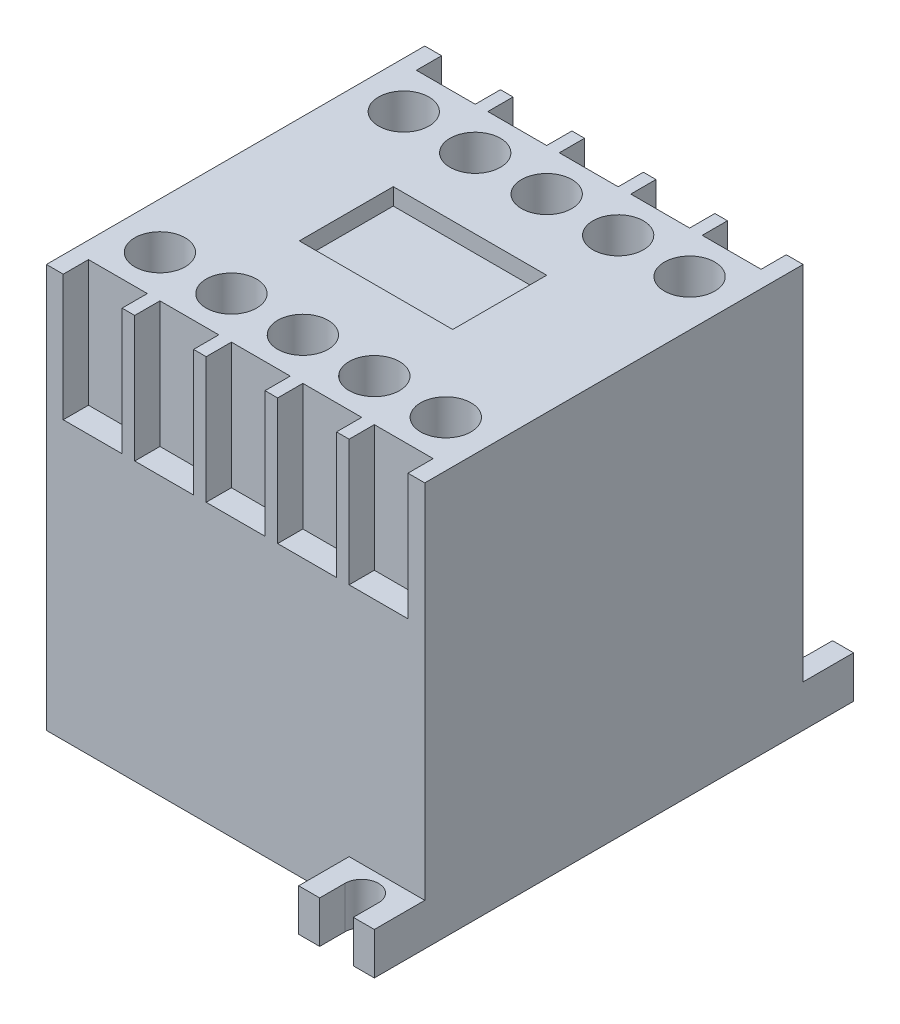
from build123d import *

# Parameters (mm, degrees)
SKETCH1_W           = 45
SKETCH1_H           = 45
BOSS_EXTRUDE1_DEPTH = 48
SKETCH2_W           = 7
SKETCH2_H           = 3
CUT_EXTRUDE1_DEPTH  = 15
SKETCH3_R           = 3
CUT_EXTRUDE2_DEPTH  = 8
SKETCH4_W           = 18.249611446
SKETCH4_H           = 11.178416291
CUT_EXTRUDE3_DEPTH  = 2
BOSS_EXTRUDE2_DEPTH = 5


with BuildPart() as part:
    # Sketch1 → Boss-Extrude1 (new body)
    with BuildSketch(Plane(origin=(0, 0, 0), x_dir=(1, 0, 0), z_dir=(0, 1, 0))):
        with Locations((22.5, 22.5)):
            Rectangle(SKETCH1_W, SKETCH1_H)
    extrude(amount=BOSS_EXTRUDE1_DEPTH)

    # Sketch2 → Cut-Extrude1 (cut)
    with BuildSketch(Plane(origin=(0, 48, 0), x_dir=(1, 0, 0), z_dir=(0, 1, 0))):
        with Locations((5.5, 1.5)):
            Rectangle(SKETCH2_W, SKETCH2_H)
        with Locations((14, 1.5)):
            Rectangle(SKETCH2_W, SKETCH2_H)
        with Locations((22.5, 1.5)):
            Rectangle(SKETCH2_W, SKETCH2_H)
        with Locations((31, 1.5)):
            Rectangle(SKETCH2_W, SKETCH2_H)
        with Locations((39.5, 1.5)):
            Rectangle(SKETCH2_W, SKETCH2_H)
        with Locations((39.5, 43.5)):
            Rectangle(SKETCH2_W, SKETCH2_H)
        with Locations((31, 43.5)):
            Rectangle(SKETCH2_W, SKETCH2_H)
        with Locations((22.5, 43.5)):
            Rectangle(SKETCH2_W, SKETCH2_H)
        with Locations((14, 43.5)):
            Rectangle(SKETCH2_W, SKETCH2_H)
        with Locations((5.5, 43.5)):
            Rectangle(SKETCH2_W, SKETCH2_H)
    extrude(amount=-CUT_EXTRUDE1_DEPTH, mode=Mode.SUBTRACT)

    # Sketch3 → Cut-Extrude2 (cut)
    with BuildSketch(Plane(origin=(0, 48, 0), x_dir=(1, 0, 0), z_dir=(0, 1, 0))):
        with Locations((5.5, 8)):
            Circle(SKETCH3_R)
        with Locations((14, 8)):
            Circle(SKETCH3_R)
        with Locations((22.5, 8)):
            Circle(SKETCH3_R)
        with Locations((31, 8)):
            Circle(SKETCH3_R)
        with Locations((39.5, 8)):
            Circle(SKETCH3_R)
        with Locations((39.5, 37)):
            Circle(SKETCH3_R)
        with Locations((31, 37)):
            Circle(SKETCH3_R)
        with Locations((22.5, 37)):
            Circle(SKETCH3_R)
        with Locations((14, 37)):
            Circle(SKETCH3_R)
        with Locations((5.5, 37)):
            Circle(SKETCH3_R)
    extrude(amount=-CUT_EXTRUDE2_DEPTH, mode=Mode.SUBTRACT)

    # Sketch4 → Cut-Extrude3 (cut)
    with BuildSketch(Plane(origin=(0, 48, 0), x_dir=(1, 0, 0), z_dir=(0, 1, 0))):
        with Locations((21.737835253, 23.050452318)):
            Rectangle(SKETCH4_W, SKETCH4_H)
    extrude(amount=-CUT_EXTRUDE3_DEPTH, mode=Mode.SUBTRACT)

    # Sketch5 → Boss-Extrude2 (add)
    with BuildSketch(Plane(origin=(0, 0, 0), x_dir=(-1, 0, 0), z_dir=(0, -1, 0))):
        with BuildLine():
            Line((-42.5, 48), (-42.5, 51))
            Line((-42.5, 51), (-45, 51))
            Line((-45, 51), (-45, 45))
            Line((-45, 45), (-36, 45))
            Line((-36, 45), (-36, 51))
            Line((-36, 51), (-38.5, 51))
            Line((-38.5, 51), (-38.5, 48))
            ThreePointArc((-38.5, 48), (-40.5, 46), (-42.5, 48))
        make_face()
        with BuildLine():
            Line((-45, 0), (-36, 0))
            Line((-36, 0), (-36, -6))
            Line((-36, -6), (-38.5, -6))
            Line((-38.5, -6), (-38.5, -3))
            ThreePointArc((-38.5, -3), (-40.5, -1), (-42.5, -3))
            Line((-42.5, -3), (-42.5, -6))
            Line((-42.5, -6), (-45, -6))
            Line((-45, -6), (-45, 0))
        make_face()
    extrude(amount=-BOSS_EXTRUDE2_DEPTH)


solid = part.part
